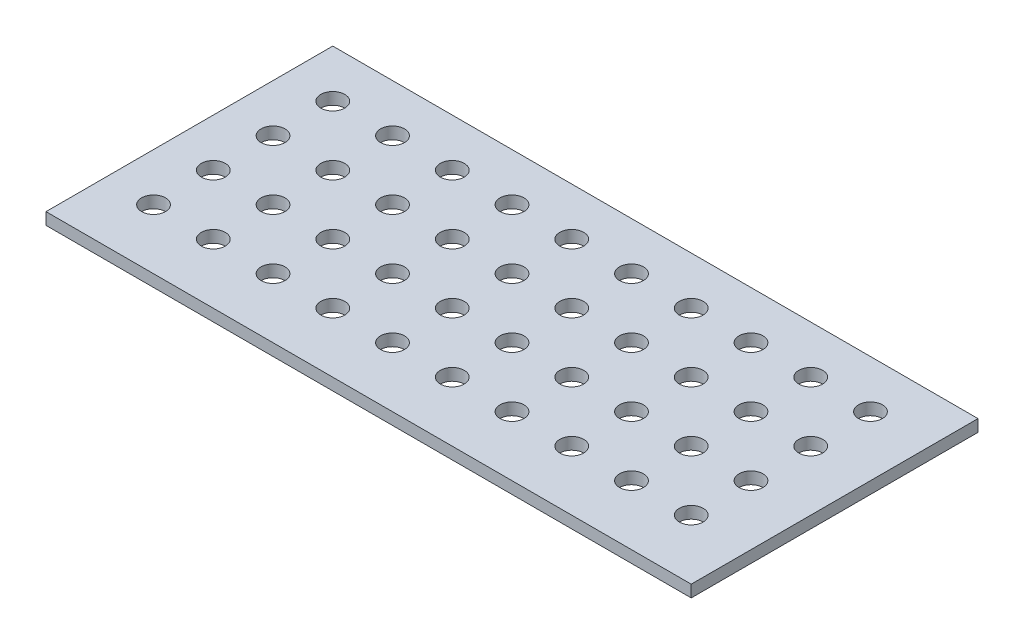
from build123d import *

# Parameters (mm, degrees)
SKETCH1_W           = 685.8
SKETCH1_H           = 304.8
BOSS_EXTRUDE1_DEPTH = 12.7
SKETCH2_R           = 12.7
CUT_EXTRUDE1_DEPTH  = 13.7


with BuildPart() as part:
    # Sketch1 → Boss-Extrude1 (new body)
    with BuildSketch(Plane(origin=(0, 0, 0), x_dir=(1, 0, 0), z_dir=(0, 1, 0))):
        Rectangle(SKETCH1_W, SKETCH1_H)
    extrude(amount=BOSS_EXTRUDE1_DEPTH)

    # Sketch2 → Cut-Extrude1 (cut, through all)
    with BuildSketch(Plane(origin=(0, 12.7, 0), x_dir=(1, 0, 0), z_dir=(0, 1, 0))):
        with Locations((-292.1, 101.6)):
            Circle(SKETCH2_R)
        with Locations((-228.6, 101.6)):
            Circle(SKETCH2_R)
        with Locations((-165.1, 101.6)):
            Circle(SKETCH2_R)
        with Locations((-101.6, 101.6)):
            Circle(SKETCH2_R)
        with Locations((-38.1, 101.6)):
            Circle(SKETCH2_R)
        with Locations((25.4, 101.6)):
            Circle(SKETCH2_R)
        with Locations((88.9, 101.6)):
            Circle(SKETCH2_R)
        with Locations((152.4, 101.6)):
            Circle(SKETCH2_R)
        with Locations((215.9, 101.6)):
            Circle(SKETCH2_R)
        with Locations((279.4, 101.6)):
            Circle(SKETCH2_R)
        with Locations((-228.6, 38.1)):
            Circle(SKETCH2_R)
        with Locations((-165.1, 38.1)):
            Circle(SKETCH2_R)
        with Locations((-101.6, 38.1)):
            Circle(SKETCH2_R)
        with Locations((-38.1, 38.1)):
            Circle(SKETCH2_R)
        with Locations((25.4, 38.1)):
            Circle(SKETCH2_R)
        with Locations((88.9, 38.1)):
            Circle(SKETCH2_R)
        with Locations((152.4, 38.1)):
            Circle(SKETCH2_R)
        with Locations((215.9, 38.1)):
            Circle(SKETCH2_R)
        with Locations((279.4, 38.1)):
            Circle(SKETCH2_R)
        with Locations((-228.6, -25.4)):
            Circle(SKETCH2_R)
        with Locations((-165.1, -25.4)):
            Circle(SKETCH2_R)
        with Locations((-101.6, -25.4)):
            Circle(SKETCH2_R)
        with Locations((-38.1, -25.4)):
            Circle(SKETCH2_R)
        with Locations((25.4, -25.4)):
            Circle(SKETCH2_R)
        with Locations((88.9, -25.4)):
            Circle(SKETCH2_R)
        with Locations((152.4, -25.4)):
            Circle(SKETCH2_R)
        with Locations((215.9, -25.4)):
            Circle(SKETCH2_R)
        with Locations((279.4, -25.4)):
            Circle(SKETCH2_R)
        with Locations((-228.6, -88.9)):
            Circle(SKETCH2_R)
        with Locations((-165.1, -88.9)):
            Circle(SKETCH2_R)
        with Locations((-101.6, -88.9)):
            Circle(SKETCH2_R)
        with Locations((-38.1, -88.9)):
            Circle(SKETCH2_R)
        with Locations((25.4, -88.9)):
            Circle(SKETCH2_R)
        with Locations((88.9, -88.9)):
            Circle(SKETCH2_R)
        with Locations((152.4, -88.9)):
            Circle(SKETCH2_R)
        with Locations((215.9, -88.9)):
            Circle(SKETCH2_R)
        with Locations((279.4, -88.9)):
            Circle(SKETCH2_R)
        with Locations((-292.1, 38.1)):
            Circle(SKETCH2_R)
        with Locations((-292.1, -25.4)):
            Circle(SKETCH2_R)
        with Locations((-292.1, -88.9)):
            Circle(SKETCH2_R)
    extrude(amount=-CUT_EXTRUDE1_DEPTH, mode=Mode.SUBTRACT)


solid = part.part
